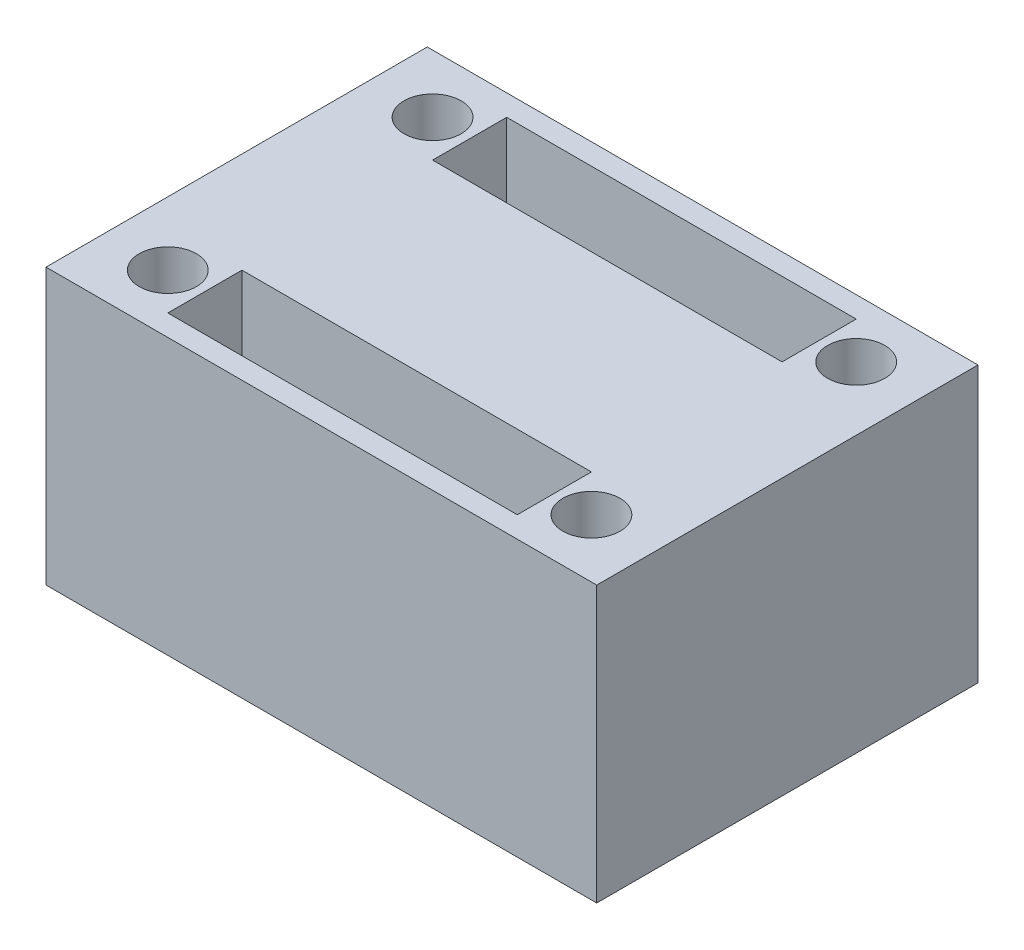
from build123d import *

# Parameters (mm, degrees)
SKETCH1_W           = 26
SKETCH1_H           = 18
BOSS_EXTRUDE1_DEPTH = 13
SKETCH2_R           = 1.35
SKETCH2_W           = 16.5
SKETCH2_H           = 3.5
CUT_EXTRUDE1_DEPTH  = 14


with BuildPart() as part:
    # Sketch1 → Boss-Extrude1 (new body)
    with BuildSketch(Plane(origin=(0, 0, 0), x_dir=(1, 0, 0), z_dir=(0, 1, 0))):
        with Locations((13, 9)):
            Rectangle(SKETCH1_W, SKETCH1_H)
    extrude(amount=BOSS_EXTRUDE1_DEPTH)

    # Sketch2 → Cut-Extrude1 (cut, through all)
    with BuildSketch(Plane(origin=(0, 13, 0), x_dir=(1, 0, 0), z_dir=(0, 1, 0))):
        with Locations((3, 15.25)):
            Circle(SKETCH2_R)
        with Locations((23, 15.25)):
            Circle(SKETCH2_R)
        with Locations((3, 2.75)):
            Circle(SKETCH2_R)
        with Locations((23, 2.75)):
            Circle(SKETCH2_R)
        with Locations((13, 15.25)):
            Rectangle(SKETCH2_W, SKETCH2_H)
        with Locations((13, 2.75)):
            Rectangle(SKETCH2_W, SKETCH2_H)
    extrude(amount=-CUT_EXTRUDE1_DEPTH, mode=Mode.SUBTRACT)


solid = part.part
